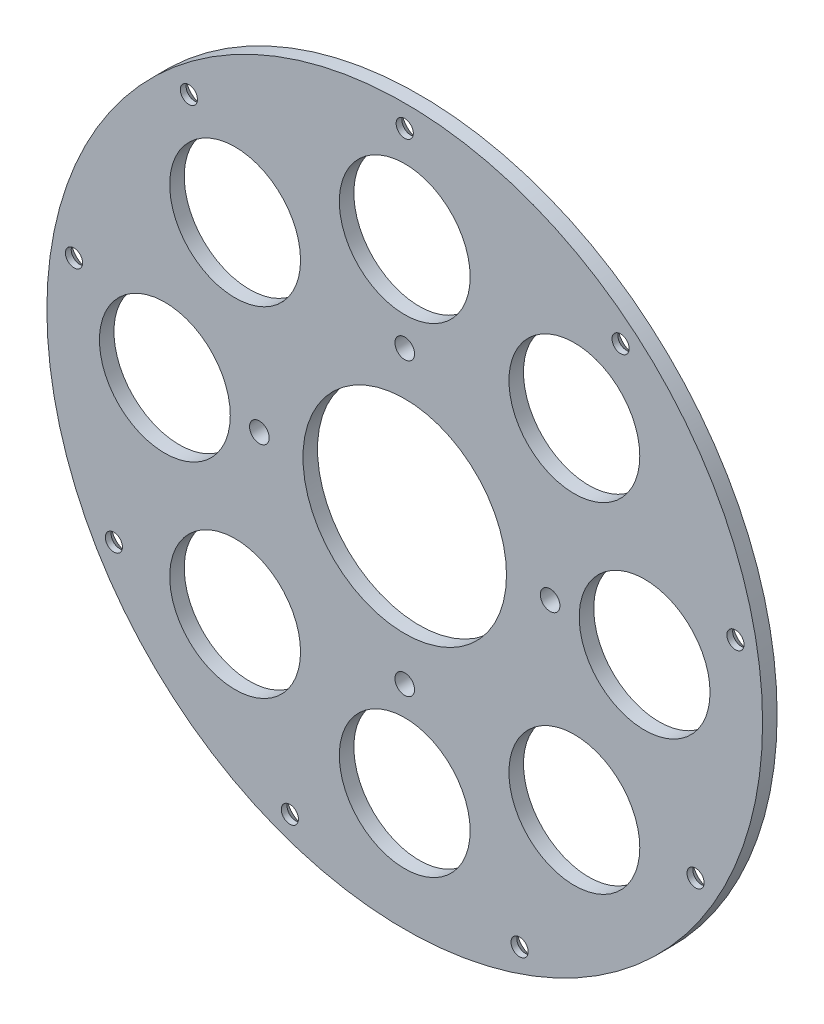
from build123d import *

# Parameters (mm, degrees)
ESQUISSE1_R        = 123.074849798
ESQUISSE1_R_2      = 2.953796395
ESQUISSE1_R_3      = 35
ESQUISSE1_R_4      = 3.375
ESQUISSE1_R_5      = 22.5
BOSS_EXTRU_1_DEPTH = 5
CHANFREIN1_SIZE    = 3


with BuildPart() as part:
    # Esquisse1 → Boss.-Extru.1 (new body)
    with BuildSketch(Plane.XY):
        Circle(ESQUISSE1_R)
        with Locations((0, 115.5)):
            Circle(ESQUISSE1_R_2, mode=Mode.SUBTRACT)
        Circle(ESQUISSE1_R_3, mode=Mode.SUBTRACT)
        with Locations((74.241968919, 88.47813318)):
            Circle(ESQUISSE1_R_2, mode=Mode.SUBTRACT)
        with Locations((113.745295473, 20.056364521)):
            Circle(ESQUISSE1_R_2, mode=Mode.SUBTRACT)
        with Locations((100.025934137, -57.75)):
            Circle(ESQUISSE1_R_2, mode=Mode.SUBTRACT)
        with Locations((39.503326554, -108.534497701)):
            Circle(ESQUISSE1_R_2, mode=Mode.SUBTRACT)
        with Locations((-39.503326554, -108.534497701)):
            Circle(ESQUISSE1_R_2, mode=Mode.SUBTRACT)
        with Locations((-100.025934137, -57.75)):
            Circle(ESQUISSE1_R_2, mode=Mode.SUBTRACT)
        with Locations((-113.745295473, 20.056364521)):
            Circle(ESQUISSE1_R_2, mode=Mode.SUBTRACT)
        with Locations((-74.241968919, 88.47813318)):
            Circle(ESQUISSE1_R_2, mode=Mode.SUBTRACT)
        with Locations((0, 50)):
            Circle(ESQUISSE1_R_4, mode=Mode.SUBTRACT)
        with Locations((50, 0)):
            Circle(ESQUISSE1_R_4, mode=Mode.SUBTRACT)
        with Locations((0, -50)):
            Circle(ESQUISSE1_R_4, mode=Mode.SUBTRACT)
        with Locations((-50, 0)):
            Circle(ESQUISSE1_R_4, mode=Mode.SUBTRACT)
        with Locations((0, 82.5)):
            Circle(ESQUISSE1_R_5, mode=Mode.SUBTRACT)
        with Locations((58.336309448, 58.336309448)):
            Circle(ESQUISSE1_R_5, mode=Mode.SUBTRACT)
        with Locations((82.5, 0)):
            Circle(ESQUISSE1_R_5, mode=Mode.SUBTRACT)
        with Locations((58.336309448, -58.336309448)):
            Circle(ESQUISSE1_R_5, mode=Mode.SUBTRACT)
        with Locations((0, -82.5)):
            Circle(ESQUISSE1_R_5, mode=Mode.SUBTRACT)
        with Locations((-58.336309448, -58.336309448)):
            Circle(ESQUISSE1_R_5, mode=Mode.SUBTRACT)
        with Locations((-82.5, 0)):
            Circle(ESQUISSE1_R_5, mode=Mode.SUBTRACT)
        with Locations((-58.336309448, 58.336309448)):
            Circle(ESQUISSE1_R_5, mode=Mode.SUBTRACT)
    extrude(amount=BOSS_EXTRU_1_DEPTH)

    # Chanfrein1
    chanfrein1_edges = [part.edges().sort_by_distance(p)[0] for p in [
        (71.288172524, 88.47813318, 0),
        (110.791499078, 20.056364521, 0),
        (97.072137742, -57.75, 0),
        (36.549530159, -108.534497701, 0),
        (-42.457122949, -108.534497701, 0),
        (-102.979730532, -57.75, 0),
        (-116.699091868, 20.056364521, 0),
        (-77.195765314, 88.47813318, 0),
        (-2.953796395, 115.5, 0),
    ]]
    chamfer(chanfrein1_edges, length=CHANFREIN1_SIZE)


solid = part.part
